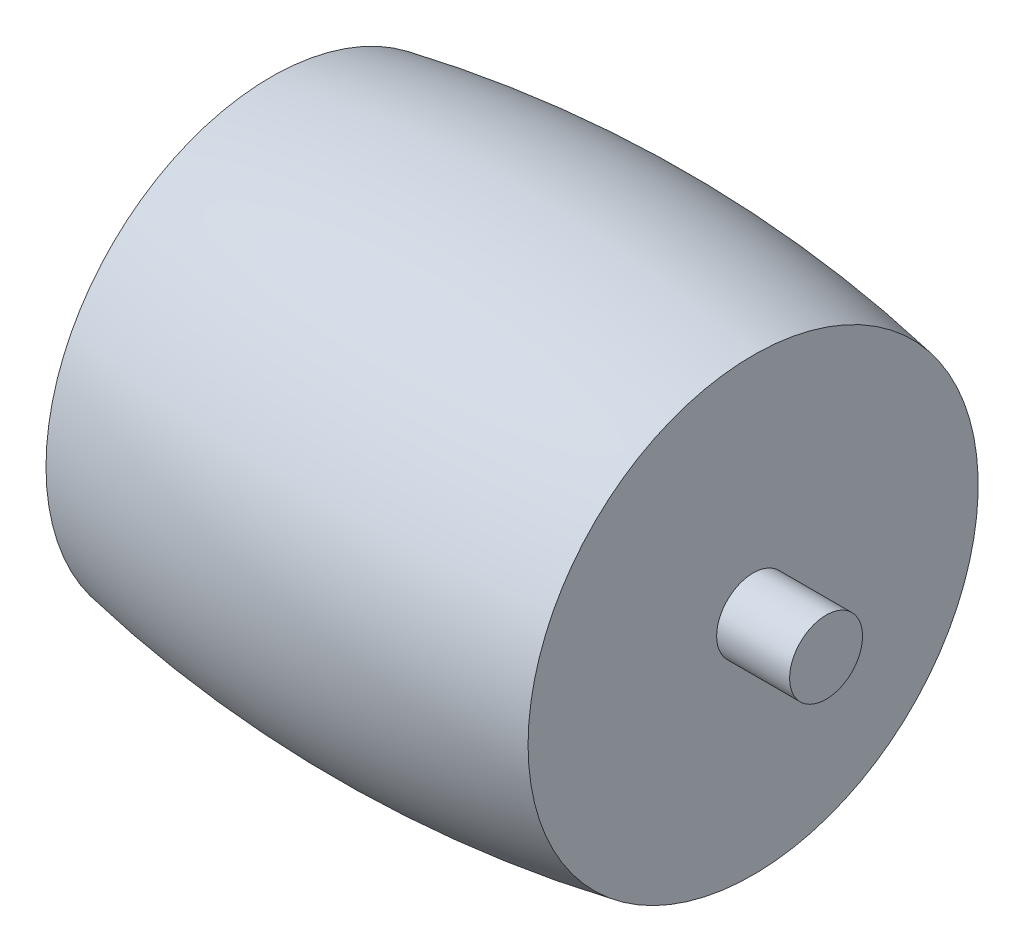
from build123d import *


with BuildPart() as part:
    # Sketch1 → Revolve1 (revolve)
    with BuildSketch(Plane.XY):
        with BuildLine():
            Line((9.25, 49.136926033), (9.25, 41.9))
            Line((9.25, 41.9), (12.05, 41.9))
            Line((12.05, 41.9), (12.05, 40.5))
            Line((12.05, 40.5), (9.25, 40.5))
            Line((9.25, 40.5), (-9.25, 40.5))
            Line((-9.25, 40.5), (-12.05, 40.5))
            Line((-12.05, 40.5), (-12.05, 41.9))
            Line((-12.05, 41.9), (-9.25, 41.9))
            Line((-9.25, 41.9), (-9.25, 49.136926033))
            ThreePointArc((-9.25, 49.136926033), (0, 50), (9.25, 49.136926033))
        make_face()
    revolve(axis=Axis((-9.25, 40.5, 0), (1, 0, 0)))


solid = part.part
